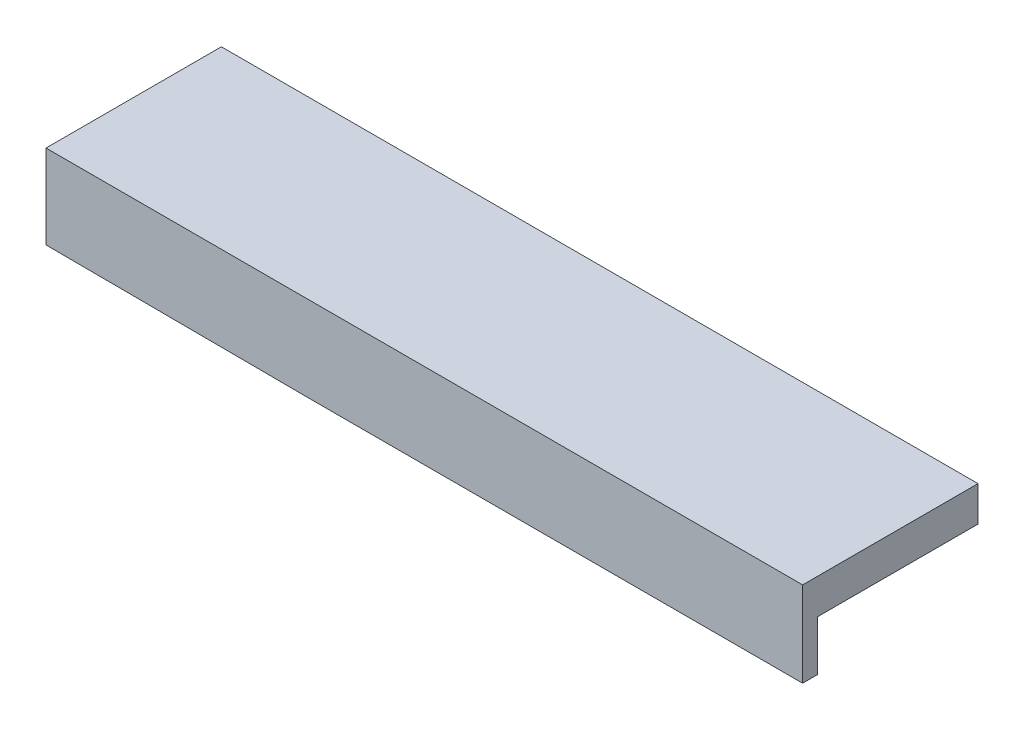
from build123d import *

# Parameters (mm, degrees)
BOSS_EXTRUDE1_DEPTH = 35
BOSS_EXTRUDE2_REACH = 94.65
SKETCH5_W           = 3
SKETCH5_H           = 10
BOSS_EXTRUDE3_REACH = 54.382
SKETCH6_W           = 3
SKETCH6_H           = 10.000117819
SKETCH7_W           = 3
SKETCH7_H           = 10
BOSS_EXTRUDE4_DEPTH = 52.35


with BuildPart() as part:
    # Sketch1 → Boss-Extrude1 (new body)
    with BuildSketch(Plane.XY):
        Polygon((-75.5, 3.5), (75.5, 3.5), (75.5, -3.5), (23.15, -3.5), (23.15, -13.5), (17.15, -13.5), (17.15, -3.5), (-17.15, -3.5), (-17.2, -13.5), (-23.199999999, -13.499882182), (-23.151457837, -3.5), (-75.5, -3.5), align=None)
    extrude(amount=BOSS_EXTRUDE1_DEPTH)

    # Boss-Extrude2: up to this face of the body (flat: up to its plane)
    boss_extrude2_end = Plane(part.part.faces().sort_by_distance((-17.175, -8.5, 17.5))[0])
    # Sketch5 → Boss-Extrude2 (add, up to the picked face)
    with BuildSketch(Plane.ZY.offset(-17.15), mode=Mode.PRIVATE) as boss_extrude2_sk1:
        with Locations((33.5, -8.5)):
            Rectangle(SKETCH5_W, SKETCH5_H)
    boss_extrude2_tool1 = split(extrude(boss_extrude2_sk1.sketch, amount=BOSS_EXTRUDE2_REACH, mode=Mode.PRIVATE), bisect_by=boss_extrude2_end, keep=Keep.BOTH, mode=Mode.PRIVATE)
    add(boss_extrude2_tool1.solids().sort_by_distance((17.15, -8.5, 33.5))[0])

    # Boss-Extrude3: up to this face of the body (flat: up to its plane)
    boss_extrude3_end = Plane(part.part.faces().sort_by_distance((-75.5, 0, 17.5))[0])
    # Sketch6 → Boss-Extrude3 (add, up to the picked face)
    with BuildSketch(Plane(origin=(-23.133922754, 0.112298384, 0), x_dir=(0, 0, 1), z_dir=(-0.999988218, 0.004854216, 0)), mode=Mode.PRIVATE) as boss_extrude3_sk1:
        with Locations((33.5, -8.612399854)):
            Rectangle(SKETCH6_W, SKETCH6_H)
    boss_extrude3_tool1 = split(extrude(boss_extrude3_sk1.sketch, amount=BOSS_EXTRUDE3_REACH, mode=Mode.PRIVATE), bisect_by=boss_extrude3_end, keep=Keep.BOTH, mode=Mode.PRIVATE)
    add(boss_extrude3_tool1.solids().sort_by_distance((-23.175729, -8.5, 33.5))[0])

    # Sketch7 → Boss-Extrude4 (add)
    with BuildSketch(Plane(origin=(23.15, 0, 0), x_dir=(0, 0, -1), z_dir=(1, 0, 0))):
        with Locations((-33.5, -8.5)):
            Rectangle(SKETCH7_W, SKETCH7_H)
    extrude(amount=BOSS_EXTRUDE4_DEPTH)


solid = part.part
